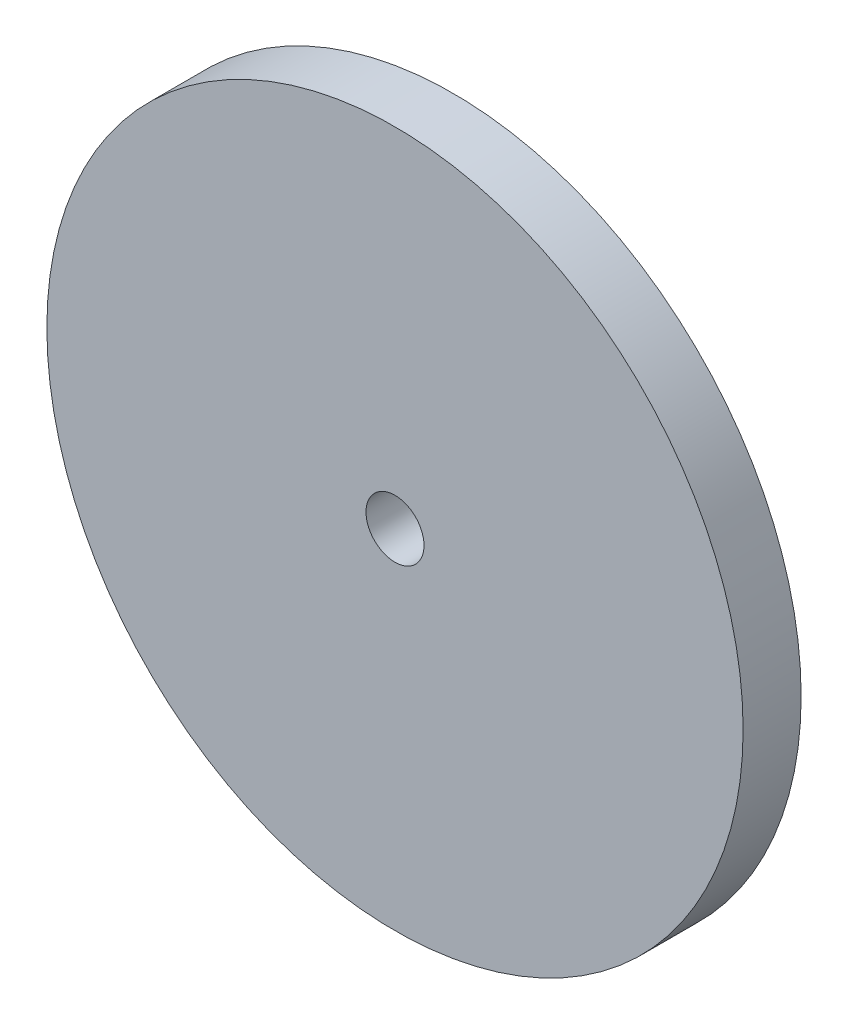
from build123d import *

# Parameters (mm, degrees)
SKETCH1_R           = 30
BOSS_EXTRUDE1_DEPTH = 5
SKETCH2_R           = 2.5
CUT_EXTRUDE1_DEPTH  = 5


with BuildPart() as part:
    # Sketch1 → Boss-Extrude1 (new body)
    with BuildSketch(Plane.XY):
        Circle(SKETCH1_R)
    extrude(amount=BOSS_EXTRUDE1_DEPTH)

    # Sketch2 → Cut-Extrude1 (cut)
    with BuildSketch(Plane.XY.offset(5)):
        Circle(SKETCH2_R)
    extrude(amount=-CUT_EXTRUDE1_DEPTH, mode=Mode.SUBTRACT)


solid = part.part
